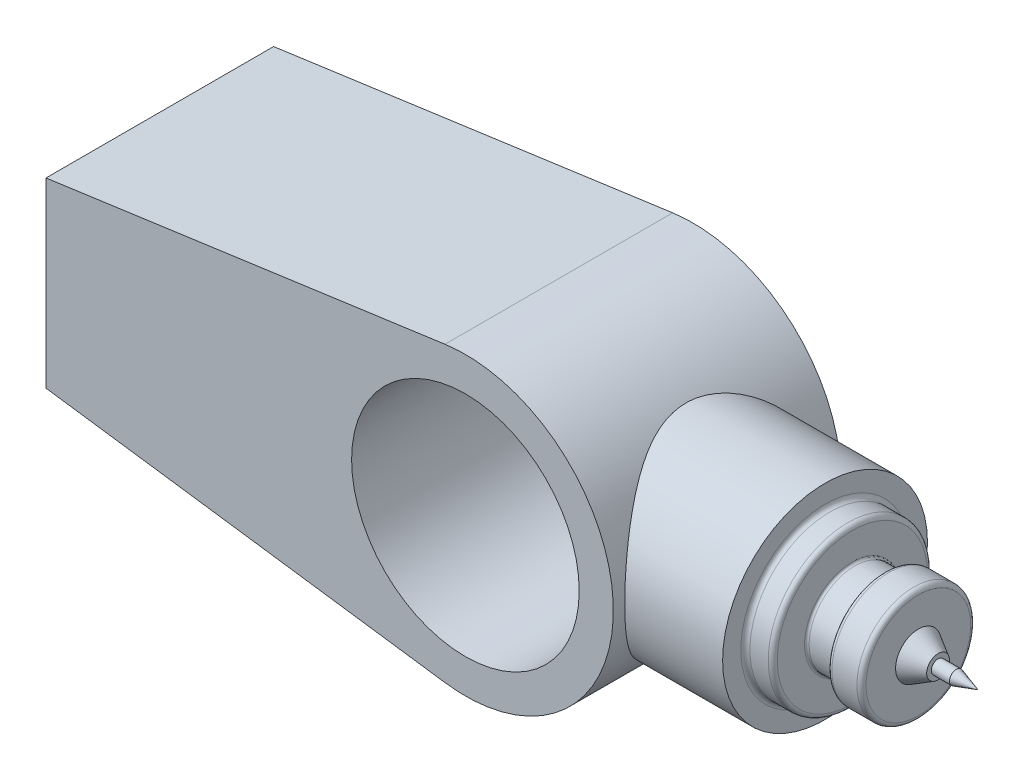
from build123d import *

# Parameters (mm, degrees)
SKETCH1_R           = 50
BOSS_EXTRUDE1_DEPTH = 50
BOSS_EXTRUDE2_REACH = 306.256
SKETCH2_R           = 45
SKETCH4_R           = 45
SKETCH4_R_2         = 35
CUT_EXTRUDE2_DEPTH  = 12
FILLET1_R           = 2
FILLET2_R           = 1


with BuildPart() as part:
    # Sketch1 → Boss-Extrude1 (new body, symmetric)
    with BuildSketch(Plane.XY):
        with BuildLine():
            Line((-184.256419232, 40), (-184.256419232, -40))
            Line((-184.256419232, -40), (-8.953748927, -64.380357099))
            ThreePointArc((-8.953748927, -64.380357099), (65, 0), (-8.953748927, 64.380357099))
            Line((-8.953748927, 64.380357099), (-184.256419232, 40))
        make_face()
        Circle(SKETCH1_R, mode=Mode.SUBTRACT)
    extrude(amount=BOSS_EXTRUDE1_DEPTH, both=True)

    # Sketch2 → Boss-Extrude2 (add, up to next)
    with BuildSketch(Plane(origin=(120, 0, 0), x_dir=(0, 0, -1), z_dir=(1, 0, 0)), mode=Mode.PRIVATE) as boss_extrude2_sk1:
        Circle(SKETCH2_R)
    boss_extrude2_tool1 = extrude(boss_extrude2_sk1.sketch, amount=-BOSS_EXTRUDE2_REACH, mode=Mode.PRIVATE) - part.part
    add(boss_extrude2_tool1.solids().sort_by_distance((120, 0, 0))[0])

    # Sketch3 → Revolve1 (revolve)
    with BuildSketch(Plane.XY):
        Polygon((120, 0), (120, -20), (134, -20), (134, -25), (149, -25), (149, -10), (157.660254038, -5), (157.660254038, -3), (165.660254038, -3), (175.199646052, 0), align=None)
    revolve(axis=Axis((0, 0, 0), (1, 0, 0)))

    # Sketch4 → Cut-Extrude2 (cut)
    with BuildSketch(Plane(origin=(120, 0, 0), x_dir=(0, 0, -1), z_dir=(1, 0, 0))):
        Circle(SKETCH4_R)
        Circle(SKETCH4_R_2, mode=Mode.SUBTRACT)
    extrude(amount=-CUT_EXTRUDE2_DEPTH, mode=Mode.SUBTRACT)

    # Fillet1
    fillet1_edges = [part.edges().sort_by_distance(p)[0] for p in [
        (134, 25, 0),
        (149, 25, 0),
        (108, 0, 35),
        (120, 0, 35),
    ]]
    fillet(fillet1_edges, radius=FILLET1_R)

    # Fillet2
    fillet2_edges = [part.edges().sort_by_distance(p)[0] for p in [
        (120, 20, 0),
        (134, 20, 0),
    ]]
    fillet(fillet2_edges, radius=FILLET2_R)


solid = part.part
